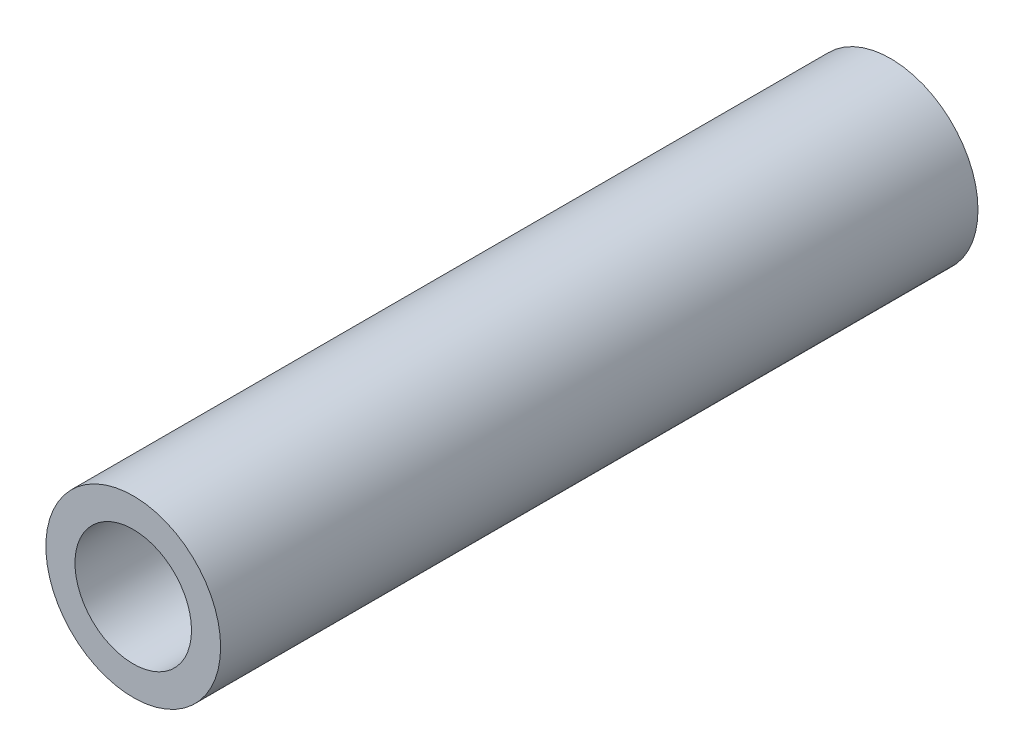
from build123d import *

# Parameters (mm, degrees)
SKETCH1_R           = 1.5
SKETCH1_R_2         = 1
BOSS_EXTRUDE1_DEPTH = 13


with BuildPart() as part:
    # Sketch1 → Boss-Extrude1 (new body)
    with BuildSketch(Plane.XY):
        Circle(SKETCH1_R)
        Circle(SKETCH1_R_2, mode=Mode.SUBTRACT)
    extrude(amount=BOSS_EXTRUDE1_DEPTH)


solid = part.part
